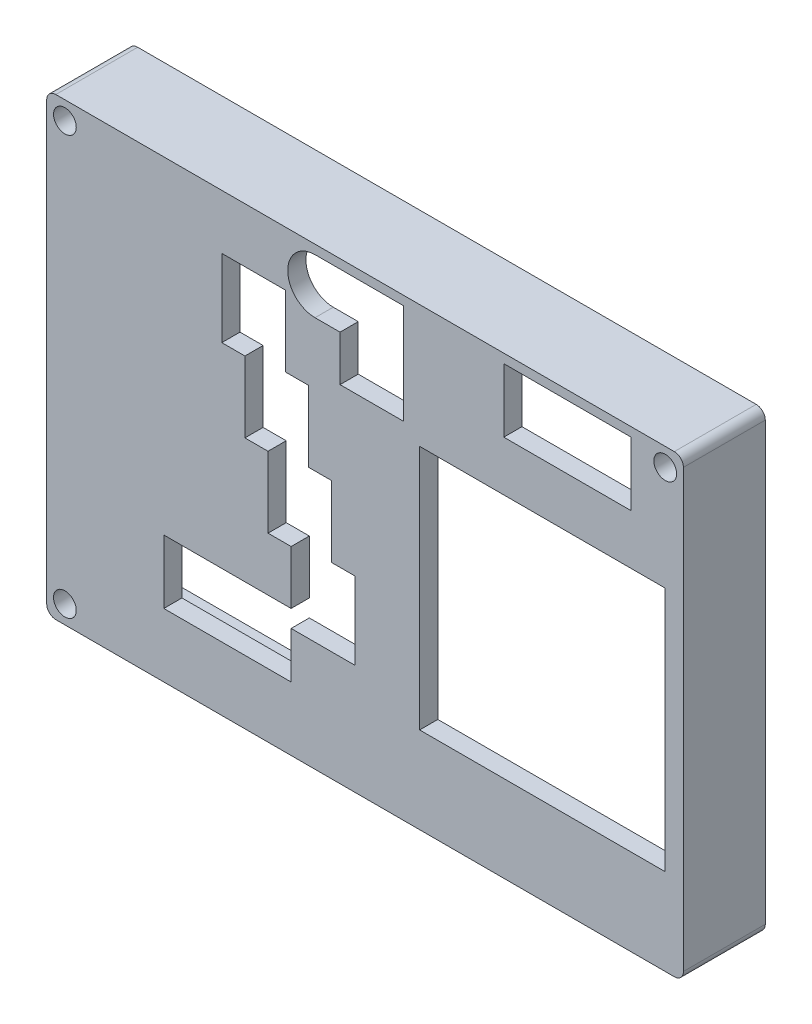
from build123d import *

# Parameters (mm, degrees)
SKETCH2_W           = 70
SKETCH2_H           = 50
SKETCH2_R           = 1.25
SKETCH2_W_2         = 27
SKETCH2_H_2         = 27
SKETCH2_W_3         = 14
SKETCH2_H_3         = 7
BOSS_EXTRUDE1_DEPTH = 2
SKETCH4_W           = 70
SKETCH4_H           = 50
SKETCH4_R           = 1.25
BOSS_EXTRUDE2_DEPTH = 7
FILLET1_R           = 1


with BuildPart() as part:
    # Sketch2 → Boss-Extrude1 (new body)
    with BuildSketch(Plane.XY):
        Rectangle(SKETCH2_W, SKETCH2_H)
        with Locations((-33, 23)):
            Circle(SKETCH2_R, mode=Mode.SUBTRACT)
        with Locations((33, 23)):
            Circle(SKETCH2_R, mode=Mode.SUBTRACT)
        with Locations((-33, -23)):
            Circle(SKETCH2_R, mode=Mode.SUBTRACT)
        with Locations((19.5, -2)):
            Rectangle(SKETCH2_W_2, SKETCH2_H_2, mode=Mode.SUBTRACT)
        Polygon((-22.13, -11), (-8.13, -11), (-8.13, -5.1), (-10.67, -5.1), (-10.67, 2.7), (-13.21, 2.7), (-13.21, 10.5), (-15.75, 10.5), (-15.75, 19), (-8.75, 19), (-8.75, 11.2), (-6.21, 11.2), (-6.21, 3.4), (-3.67, 3.4), (-3.67, -4.4), (-1.13, -4.4), (-1.13, -12.9), (-8.13, -12.9), (-8.13, -18), (-22.13, -18), align=None, mode=Mode.SUBTRACT)
        with BuildLine():
            Line((-2.75, 24), (4.25, 24))
            Line((4.25, 24), (4.25, 13))
            Line((4.25, 13), (-2.75, 13))
            Line((-2.75, 13), (-2.75, 18))
            Line((-2.75, 18), (-5.5, 18))
            ThreePointArc((-5.5, 18), (-8.5, 21), (-5.5, 24))
            Line((-5.5, 24), (-2.75, 24))
        make_face(mode=Mode.SUBTRACT)
        with Locations((22.25, 20.5)):
            Rectangle(SKETCH2_W_3, SKETCH2_H_3, mode=Mode.SUBTRACT)
    extrude(amount=BOSS_EXTRUDE1_DEPTH)

    # Sketch4 → Boss-Extrude2 (add)
    with BuildSketch(Plane(origin=(0, 0, 0), x_dir=(-1, 0, 0), z_dir=(0, 0, -1))):
        Rectangle(SKETCH4_W, SKETCH4_H)
        with Locations((-33, 23)):
            Circle(SKETCH4_R, mode=Mode.SUBTRACT)
        with Locations((33, 23)):
            Circle(SKETCH4_R, mode=Mode.SUBTRACT)
        with Locations((33, -23)):
            Circle(SKETCH4_R, mode=Mode.SUBTRACT)
        with BuildLine():
            Line((-30.984435563, 24), (30.984435563, 24))
            ThreePointArc((30.984435563, 24), (31.409009742, 21.409009742), (34, 20.984435563))
            Line((34, 20.984435563), (34, -20.984435563))
            ThreePointArc((34, -20.984435563), (31.409009742, -21.409009742), (30.984435563, -24))
            Line((30.984435563, -24), (-34, -24))
            Line((-34, -24), (-34, 20.984435563))
            ThreePointArc((-34, 20.984435563), (-31.409009742, 21.409009742), (-30.984435563, 24))
        make_face(mode=Mode.SUBTRACT)
    extrude(amount=BOSS_EXTRUDE2_DEPTH)

    # Fillet1
    fillet1_edges = [part.edges().sort_by_distance(p)[0] for p in [
        (35, -25, -2.5),
        (-35, -25, -2.5),
        (-35, 25, -2.5),
        (35, 25, -2.5),
    ]]
    fillet(fillet1_edges, radius=FILLET1_R)


solid = part.part
